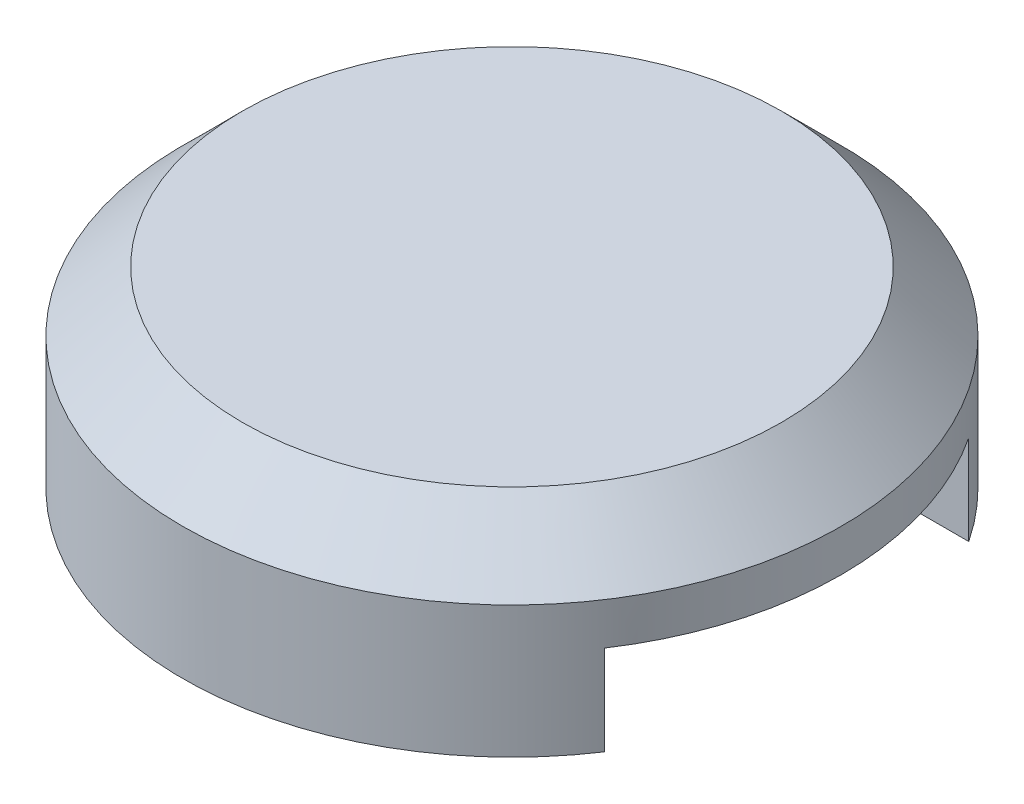
from build123d import *

# Parameters (mm, degrees)
SKETCH1_R           = 5.5
BOSS_EXTRUDE1_DEPTH = 3.2
CHAMFER2_SIZE       = 1
SHELL1_T            = -1.2
SKETCH4_W           = 6.081118318
SKETCH4_H           = 6.081118318
CUT_EXTRUDE1_DEPTH  = 1.5


with BuildPart() as part:
    # Sketch1 → Boss-Extrude1 (new body)
    with BuildSketch(Plane(origin=(0, 0, 0), x_dir=(1, 0, 0), z_dir=(0, 1, 0))):
        with Locations(Location((0, 0, 0), (0, 0, 270))):
            Circle(SKETCH1_R)
    extrude(amount=BOSS_EXTRUDE1_DEPTH)

    # Chamfer2
    chamfer2_edges = [part.edges().sort_by_distance(p)[0] for p in [
        (0, 3.2, -5.5),
    ]]
    chamfer(chamfer2_edges, length=CHAMFER2_SIZE)

    # Shell1
    shell1_openings = [part.faces().sort_by_distance(p)[0] for p in [
        (0, 0, 0),
    ]]
    offset(amount=SHELL1_T, openings=shell1_openings, kind=Kind.INTERSECTION)

    # Sketch4 → Cut-Extrude1 (cut)
    with BuildSketch(Plane.XZ):
        with Locations((6.081118318, 0)):
            Rectangle(SKETCH4_W, SKETCH4_H)
    extrude(amount=-CUT_EXTRUDE1_DEPTH, mode=Mode.SUBTRACT)


solid = part.part
